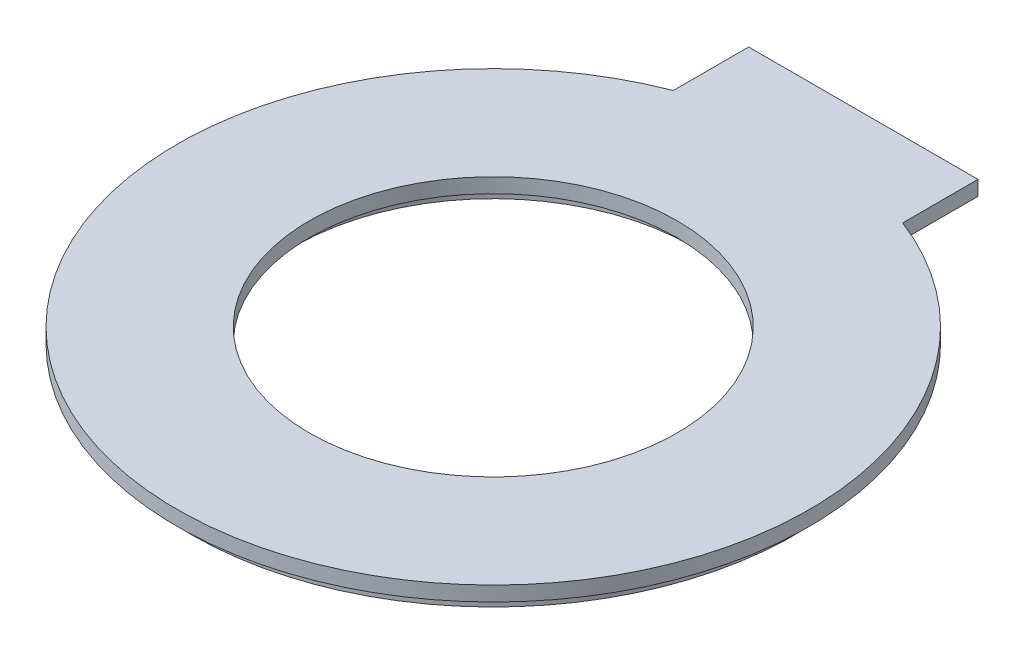
from build123d import *

# Parameters (mm, degrees)
SKETCH1_R           = 12.5
BOSS_EXTRUDE1_DEPTH = 1
SKETCH2_R           = 13.5
BOSS_EXTRUDE2_DEPTH = 1


with BuildPart() as part:
    # Sketch1 → Boss-Extrude1 (new body)
    with BuildSketch(Plane(origin=(0, 0, 0), x_dir=(1, 0, 0), z_dir=(0, 1, 0))):
        with BuildLine():
            Line((-7.795, 20.037164844), (-7.795, 25.157164844))
            Line((-7.795, 25.157164844), (7.795, 25.157164844))
            Line((7.795, 25.157164844), (7.795, 20.037164844))
            ThreePointArc((7.795, 20.037164844), (0, -21.5), (-7.795, 20.037164844))
        make_face()
        Circle(SKETCH1_R, mode=Mode.SUBTRACT)
    extrude(amount=BOSS_EXTRUDE1_DEPTH)

    # Sketch2 → Boss-Extrude2 (add)
    with BuildSketch(Plane.XZ):
        with BuildLine():
            Line((-6.795, -24.157164844), (6.795, -24.157164844))
            Line((6.795, -24.157164844), (6.795, -19.341095496))
            ThreePointArc((6.795, -19.341095496), (0, 20.5), (-6.795, -19.341095496))
            Line((-6.795, -19.341095496), (-6.795, -24.157164844))
        make_face()
        Circle(SKETCH2_R, mode=Mode.SUBTRACT)
    extrude(amount=BOSS_EXTRUDE2_DEPTH)


solid = part.part
